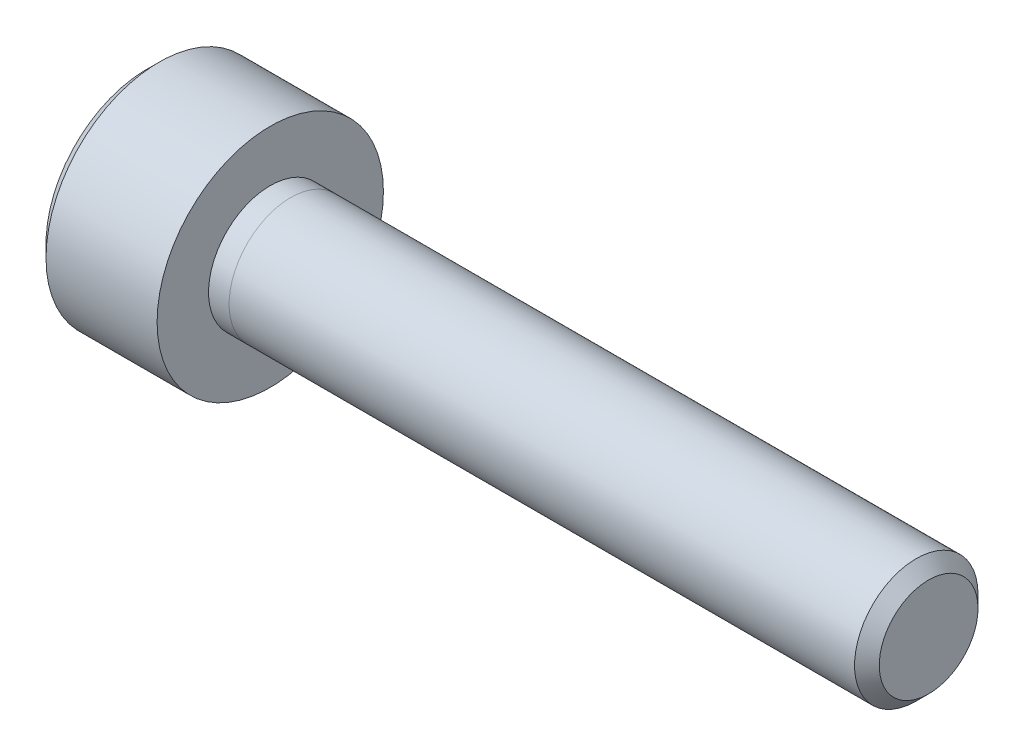
from build123d import *

# Parameters (mm, degrees)
SKETCH_1_R          = 2.75
EXTRUDE_1_DEPTH     = 3
SKETCH_2_R          = 1.5
EXTRUDE_2_DEPTH     = 0.5
CHAMFER_2_SIZE      = 0.3
CUT_EXTRUDE_1_DEPTH = 2.2
SKETCH_11_R         = 1.5
EXTRUDE_6_DEPTH     = 15.5
CHAMFER_3_SIZE      = 0.3


with BuildPart() as part:
    # 草图1 → 凸台-拉伸1 (new body)
    with BuildSketch(Plane(origin=(0, 0, 0), x_dir=(0, 0, -1), z_dir=(1, 0, 0))):
        Circle(SKETCH_1_R)
    extrude(amount=EXTRUDE_1_DEPTH)

    # 草图2 → 凸台-拉伸2 (add)
    with BuildSketch(Plane(origin=(3, 0, 0), x_dir=(0, 0, -1), z_dir=(1, 0, 0))):
        Circle(SKETCH_2_R)
    extrude(amount=EXTRUDE_2_DEPTH)

    # 倒角2
    chamfer_2_edges = [part.edges().sort_by_distance(p)[0] for p in [
        (0, 0, 2.75),
    ]]
    chamfer(chamfer_2_edges, length=CHAMFER_2_SIZE)

    # 草图5 → 切除-拉伸1 (cut)
    with BuildSketch(Plane.ZY):
        Polygon((1.430744137, 0.190537526), (0.550361731, 1.334329531), (-0.880382406, 1.143792006), (-1.430744137, -0.190537526), (-0.550361731, -1.334329531), (0.880382406, -1.143792006), align=None)
    extrude(amount=-CUT_EXTRUDE_1_DEPTH, mode=Mode.SUBTRACT)


with BuildPart() as body_2:
    # 草图11 → 凸台-拉伸6 (new body)
    with BuildSketch(Plane(origin=(3.5, 0, 0), x_dir=(0, 0, -1), z_dir=(1, 0, 0))):
        Circle(SKETCH_11_R)
    extrude(amount=EXTRUDE_6_DEPTH)

    # 倒角3
    chamfer_3_edges = [body_2.edges().sort_by_distance(p)[0] for p in [
        (19, 0, 1.5),
    ]]
    chamfer(chamfer_3_edges, length=CHAMFER_3_SIZE)


solid = Compound([part.part, body_2.part])
